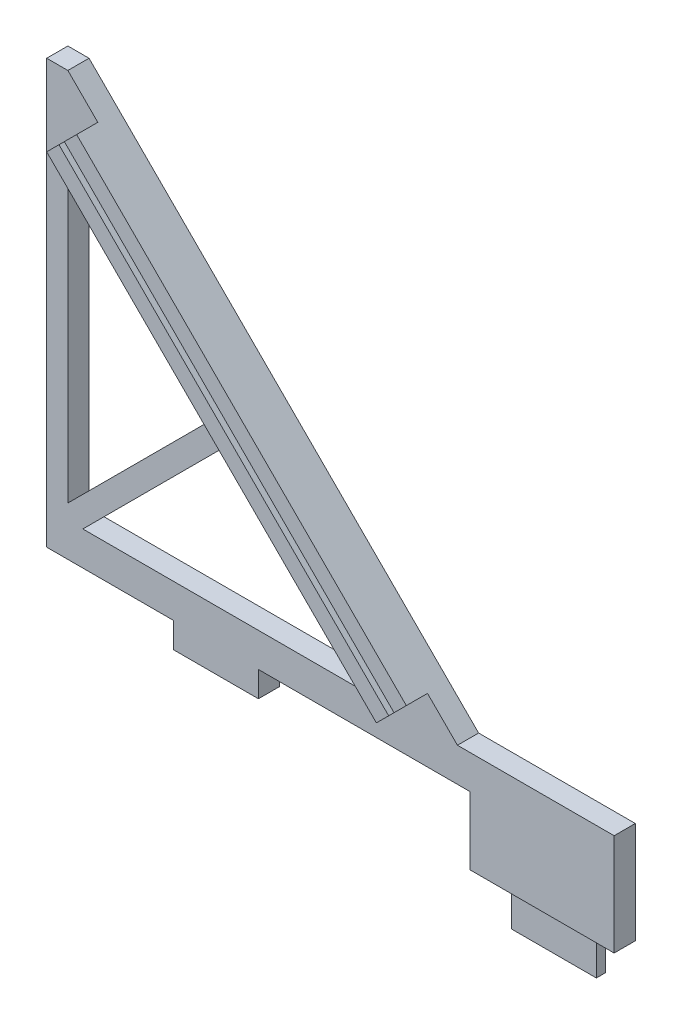
from build123d import *

# Parameters (mm, degrees)
BOSS_EXTRUDE1_DEPTH = 3.175
SKETCH5_W           = 12.7
SKETCH5_H           = 6.35
CUT_EXTRUDE2_DEPTH  = 1.778
BOSS_EXTRUDE3_DEPTH = 3.175


with BuildPart() as part:
    # Sketch2 → Boss-Extrude1 (new body)
    with BuildSketch(Plane.XY):
        Polygon((0, 0), (12.7, 0), (12.7, 6.35), (17.145, 6.35), (17.145, 21.59), (-6.35, 21.59), (-64.77, 80.01), (-67.945, 80.01), (-67.945, 16.51), (-48.895, 16.51), (-48.895, 12.7), (-36.195, 12.7), (-36.195, 16.51), (-4.445, 16.51), (-4.445, 6.35), (0, 6.35), align=None)
        Polygon((-64.77, 71.029743879), (-64.77, 23.83506403), (-41.172660076, 47.432403955), align=None, mode=Mode.SUBTRACT)
        Polygon((-62.52493597, 21.59), (-15.330256121, 21.59), (-38.927596045, 45.187339924), align=None, mode=Mode.SUBTRACT)
    extrude(amount=BOSS_EXTRUDE1_DEPTH)

    # Sketch5 → Cut-Extrude2 (cut)
    with BuildSketch(Plane.XY.offset(3.175)):
        with Locations((6.35, 3.175)):
            Rectangle(SKETCH5_W, SKETCH5_H)
    extrude(amount=-CUT_EXTRUDE2_DEPTH, mode=Mode.SUBTRACT)

    # Sketch6 → Boss-Extrude3 (add)
    with BuildSketch(Plane.XY.offset(3.175)):
        Polygon((-15.330256121, 21.59), (-64.77, 71.029743879), (-62.929047495, 72.870696384), (-13.489303616, 23.430952505), align=None)
        Polygon((-10.840128061, 26.080128061), (-12.681080565, 24.239175556), (-62.120824444, 73.678919435), (-60.279871939, 75.519871939), align=None)
    extrude(amount=BOSS_EXTRUDE3_DEPTH)


solid = part.part
